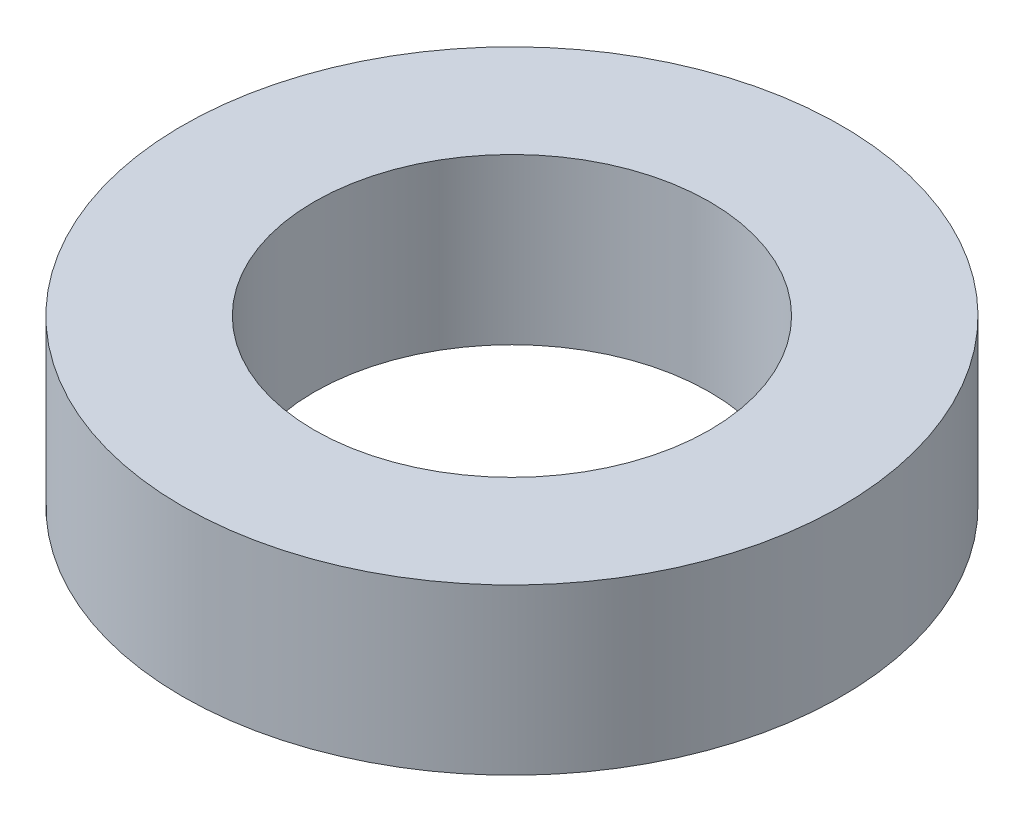
from build123d import *

# Parameters (mm, degrees)
SKETCH1_R           = 6.35
SKETCH1_R_2         = 3.81
BOSS_EXTRUDE1_DEPTH = 3.175


with BuildPart() as part:
    # Sketch1 → Boss-Extrude1 (new body)
    with BuildSketch(Plane(origin=(0, 0, 0), x_dir=(1, 0, 0), z_dir=(0, 1, 0))):
        Circle(SKETCH1_R)
        Circle(SKETCH1_R_2, mode=Mode.SUBTRACT)
    extrude(amount=BOSS_EXTRUDE1_DEPTH)


solid = part.part
